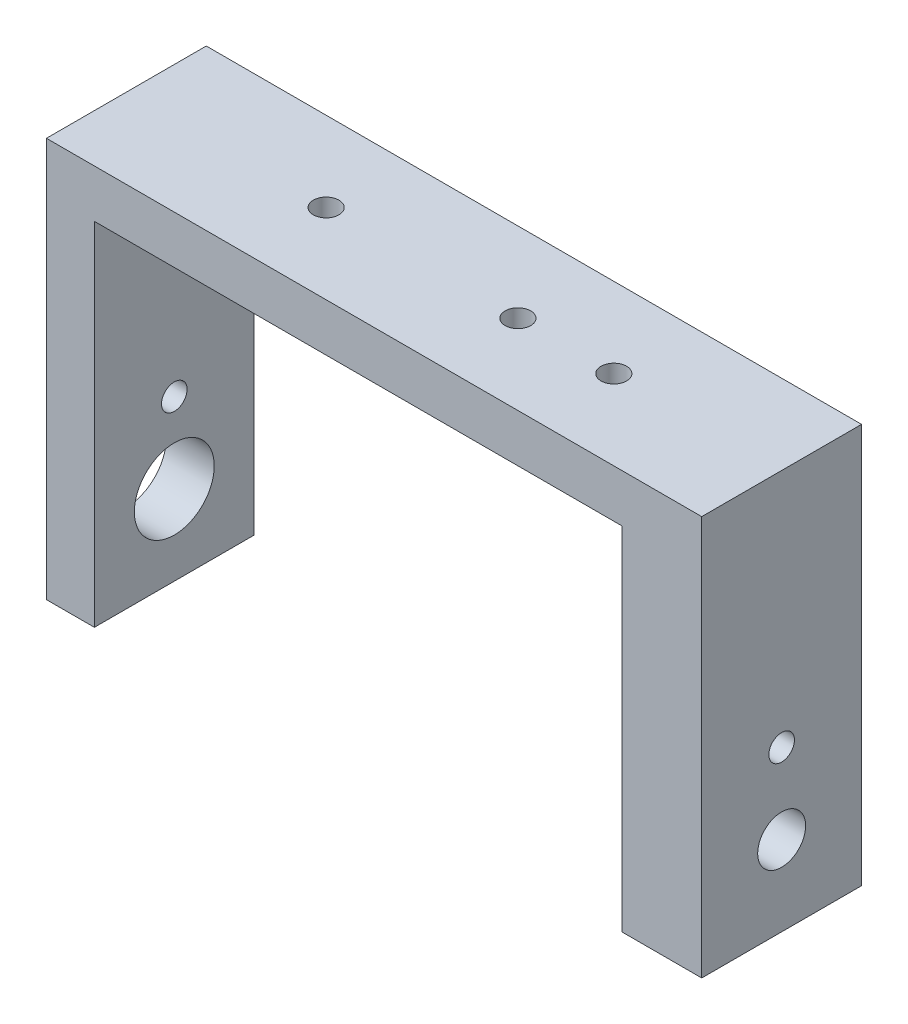
from build123d import *

# Parameters (mm, degrees)
BOSS_EXTRUDE1_DEPTH = 10
SKETCH4_R           = 1.5
SKETCH4_R_2         = 0.8
CUT_EXTRUDE1_DEPTH  = 42
SKETCH6_R           = 0.8
CUT_EXTRUDE2_DEPTH  = 26
CUT_EXTRUDE3_DEPTH  = 2
SKETCH9_R           = 2.5
CUT_EXTRUDE4_DEPTH  = 10


with BuildPart() as part:
    # Sketch2 → Boss-Extrude1 (new body)
    with BuildSketch(Plane.XY):
        Polygon((-16.5, -11), (-19.5, -11), (-19.5, 14), (21.5, 14), (21.5, -11), (16.5, -11), (16.5, 11), (-16.5, 11), align=None)
    extrude(amount=BOSS_EXTRUDE1_DEPTH)

    # Sketch4 → Cut-Extrude1 (cut, through all)
    with BuildSketch(Plane.ZY.offset(19.5)):
        with Locations((5, -6)):
            Circle(SKETCH4_R)
        with Locations((5, -1)):
            Circle(SKETCH4_R_2)
    extrude(amount=-CUT_EXTRUDE1_DEPTH, mode=Mode.SUBTRACT)

    # Sketch6 → Cut-Extrude2 (cut, through all)
    with BuildSketch(Plane(origin=(0, 14, 0), x_dir=(1, 0, 0), z_dir=(0, 1, 0))):
        with Locations((-7, -5)):
            Circle(SKETCH6_R)
        with Locations((11, -5)):
            Circle(SKETCH6_R)
        with Locations((5, -5)):
            Circle(SKETCH6_R)
    extrude(amount=-CUT_EXTRUDE2_DEPTH, mode=Mode.SUBTRACT)

    # Sketch8 → Cut-Extrude3 (cut)
    with BuildSketch(Plane.ZY.offset(-16.5)):
        Polygon((1, -1), (1, -11), (9, -11), (9, -1), (7, 12), (3, 12), align=None)
    extrude(amount=-CUT_EXTRUDE3_DEPTH, mode=Mode.SUBTRACT)

    # Sketch9 → Cut-Extrude4 (cut)
    with BuildSketch(Plane.ZY.offset(19.5)):
        with Locations((5, -6)):
            Circle(SKETCH9_R)
    extrude(amount=-CUT_EXTRUDE4_DEPTH, mode=Mode.SUBTRACT)


solid = part.part
